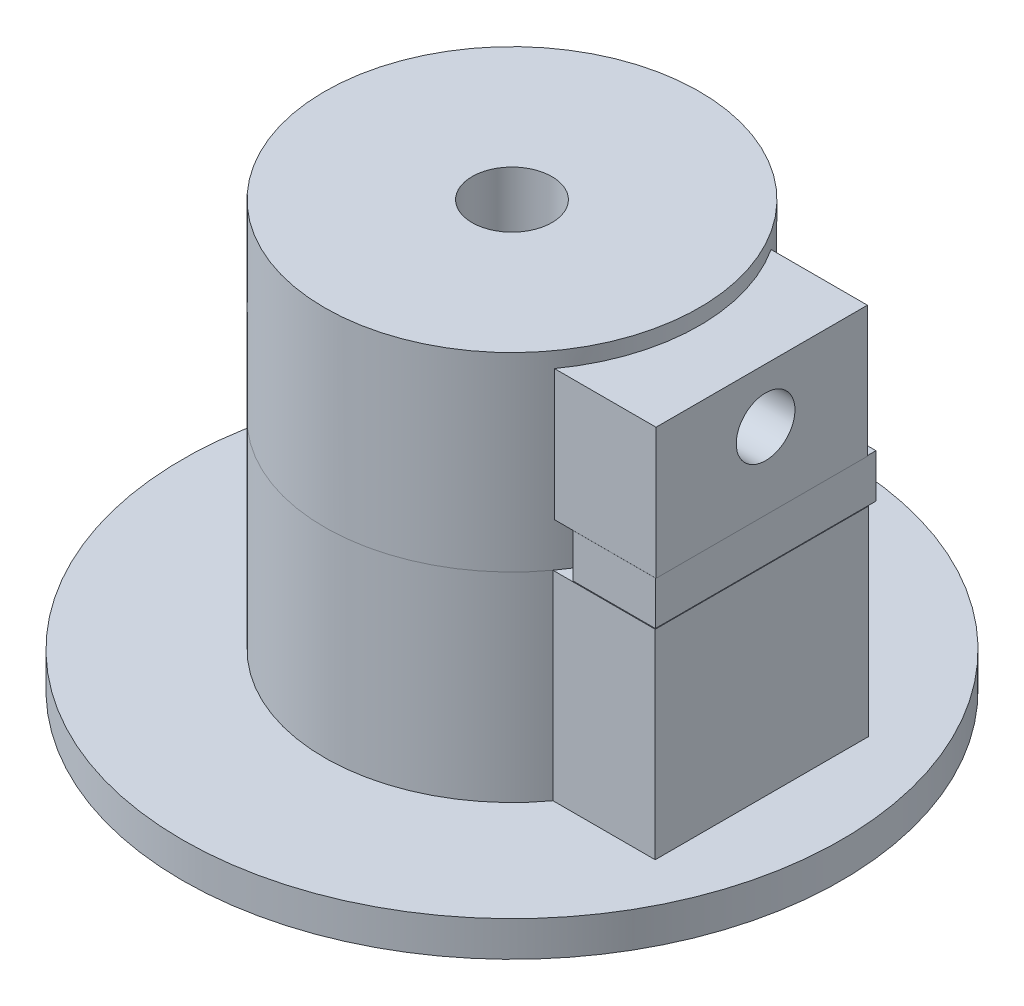
from build123d import *

# Parameters (mm, degrees)
SKETCH1_R                                      = 15.958
SHAFTHOLDERNEARMOTOR_DEPTH                     = 17.19
SKETCH2_R                                      = 3.4
SHAFTHOLE_DEPTH                                = 16.85
SKETCH5_W                                      = 1.550685087
SKETCH5_H                                      = 7.184215806
BOSS_EXTRUDE2_DEPTH                            = 13.55
SKETCH7_W                                      = 18.003976239
SKETCH7_H                                      = 11.144937805
BOSS_EXTRUDE3_DEPTH                            = 19
SKETCH6_R                                      = 2.5
BOLTHOLE_DEPTH                                 = 1
BOLTHOLE_DEPTH_BACK                            = 19
SKETCH10_R                                     = 50
BOSS_EXTRUDE4_DEPTH                            = 20
SKETCH12_R                                     = 43
SKETCH12_R_2                                   = 15.95790089
CUTTOREMVEEXCESSMATERIAL_DEPTH                 = 17
SKETCH13_R                                     = 50
SKETCH13_R_2                                   = 42.696683681
BOSS_EXTRUDE5_DEPTH                            = 17
SKETCH9_W                                      = 7.08573731
SKETCH9_H                                      = 8.730531823
NUTOPENING_DEPTH                               = 74.484692283
HEXCUT_DEPTH                                   = 7.08573731
SKETCH16_R                                     = 6
CUT_EXTRUDE7_DEPTH                             = 40
SKETCH19_R                                     = 12
CUT_EXTRUDE8_DEPTH                             = 5
SKETCH20_R                                     = 12
CUT_EXTRUDE9_DEPTH                             = 5
SKETCH22_R                                     = 12.553525499
CUT_EXTRUDE10_DEPTH                            = 5
SKETCH21_R                                     = 10
CUT_EXTRUDE11_DEPTH                            = 5
SKETCH23_R                                     = 11.965333231
CUT_EXTRUDE12_DEPTH                            = 5
SKETCH25_R                                     = 9.629681042
CUT_EXTRUDE13_DEPTH                            = 5
SKETCH26_R                                     = 15.012411299
CUT_EXTRUDE14_DEPTH                            = 5
SKETCH27_R                                     = 11.854712092
CUT_EXTRUDE15_DEPTH                            = 5
SKETCH28_W                                     = 8.838679887
SKETCH28_H                                     = 18.172415452
BOSS_EXTRUDE6_DEPTH                            = 17
SKETCH29_W                                     = 7.025540803
SKETCH29_H                                     = 18.786067296
BOSS_EXTRUDE7_DEPTH                            = 3.722722351
SKETCH31_R                                     = 26.336547497
CUT_EXTRUDE16_DEPTH                            = 1
SKETCH32_R                                     = 3.380332453
CUT_EXTRUDE17_DEPTH                            = 2
SKETCH33_R                                     = 63.32413164
SKETCH33_R_2                                   = 28.068575678
REMOVEOUTSIDEOFWHEEL_WOULDLIKETODISABLET_DEPTH = 80.806015003
CUTOUTWEDGETOMAKEBOTINSERTIONEASIER_DEPTH      = 7.085737
BOLTHOLDERDEPTHINCREASE_DEPTH                  = 7.08573731


with BuildPart() as part:
    # Sketch1 → ShaftHolderNearMotor (new body)
    with BuildSketch(Plane(origin=(0, 0, 0), x_dir=(1, 0, 0), z_dir=(0, 1, 0))):
        with Locations(Location((0, 0, 0), (0, 0, 270))):
            Circle(SKETCH1_R)
    extrude(amount=SHAFTHOLDERNEARMOTOR_DEPTH)

    # Sketch2 → ShaftHole (cut)
    with BuildSketch(Plane(origin=(0, 17.19, 0), x_dir=(1, 0, 0), z_dir=(0, 1, 0))):
        with Locations(Location((0, 0, 0), (0, 0, 270))):
            Circle(SKETCH2_R)
    extrude(amount=-SHAFTHOLE_DEPTH, mode=Mode.SUBTRACT)

    # Sketch5 → Boss-Extrude2 (add)
    with BuildSketch(Plane(origin=(0, 12.15, 0), x_dir=(1, 0, 0), z_dir=(0, 1, 0))):
        with Locations((3.375342544, 0.020519704)):
            Rectangle(SKETCH5_W, SKETCH5_H)
    extrude(amount=-BOSS_EXTRUDE2_DEPTH)

    # Sketch7 → Boss-Extrude3 (add)
    with BuildSketch(Plane.ZY.offset(-2.6)):
        with Locations((0.33027221, 9.295191254)):
            Rectangle(SKETCH7_W, SKETCH7_H)
    extrude(amount=-BOSS_EXTRUDE3_DEPTH)

    # Sketch6 → BoltHole (cut, two sides)
    with BuildSketch(Plane.ZY.offset(-2.6)) as bolthole_sk:
        with Locations(Location((0, 10.236925537, 0), (0, 0, 208.794122803))):
            Circle(SKETCH6_R)
    extrude(amount=BOLTHOLE_DEPTH, mode=Mode.SUBTRACT)
    extrude(bolthole_sk.sketch, amount=-BOLTHOLE_DEPTH_BACK, mode=Mode.SUBTRACT)

    # Sketch10 → Boss-Extrude4 (add)
    with BuildSketch(Plane.XZ):
        with Locations(Location((0, 0, 0), (0, 0, 270))):
            Circle(SKETCH10_R)
    extrude(amount=BOSS_EXTRUDE4_DEPTH)

    # Sketch12 → CutToRemveExcessMaterial (cut)
    with BuildSketch(Plane(origin=(0, 0, 0), x_dir=(1, 0, 0), z_dir=(0, 1, 0))):
        with Locations(Location((0, 0, 0), (0, 0, 270))):
            Circle(SKETCH12_R)
        with Locations(Location((0, 0, 0), (0, 0, 270))):
            Circle(SKETCH12_R_2, mode=Mode.SUBTRACT)
    extrude(amount=-CUTTOREMVEEXCESSMATERIAL_DEPTH, mode=Mode.SUBTRACT)

    # Sketch13 → Boss-Extrude5 (add)
    with BuildSketch(Plane(origin=(0, 0, 0), x_dir=(1, 0, 0), z_dir=(0, 1, 0))):
        with Locations(Location((0, 0, 0), (0, 0, 270))):
            Circle(SKETCH13_R)
        with Locations(Location((0, 0, 0), (0, 0, 270))):
            Circle(SKETCH13_R_2, mode=Mode.SUBTRACT)
    extrude(amount=BOSS_EXTRUDE5_DEPTH)

    # Sketch9 → NutOpening (cut, through all)
    with BuildSketch(Plane.XY):
        with Locations((8.411159077, 10.198209562)):
            Rectangle(SKETCH9_W, SKETCH9_H)
    extrude(amount=-NUTOPENING_DEPTH, mode=Mode.SUBTRACT)

    # Sketch14 → HexCut (cut)
    with BuildSketch(Plane.ZY.offset(-11.954027732)):
        Polygon((-4.731913408, 10.236925537), (-2.365956704, 6.138968317), (2.365956704, 6.138968317), (4.731913408, 10.236925537), (2.365956704, 14.334882757), (-2.365956704, 14.334882757), align=None)
    extrude(amount=HEXCUT_DEPTH, mode=Mode.SUBTRACT)

    # Sketch16 → Cut-Extrude7 (cut)
    with BuildSketch(Plane(origin=(21.6, 0, 0), x_dir=(0, 0, -1), z_dir=(1, 0, 0))):
        with Locations(Location((0, 10.236925537, 0), (0, 0, 180))):
            Circle(SKETCH16_R)
    extrude(amount=CUT_EXTRUDE7_DEPTH, mode=Mode.SUBTRACT)

    # Sketch19 → Cut-Extrude8 (cut)
    with BuildSketch(Plane(origin=(9.351145186, 0, 49.117777675), x_dir=(0.9823555534957298, 0, -0.18702290372063646), z_dir=(0.18702290372063649, 0, 0.9823555534957299))):
        with Locations((-6.553798813, -15.044376388)):
            Circle(SKETCH19_R)
    extrude(amount=-CUT_EXTRUDE8_DEPTH, mode=Mode.SUBTRACT)

    # Sketch20 → Cut-Extrude9 (cut)
    with BuildSketch(Plane(origin=(35.756785301, 0, 34.949281894), x_dir=(0.6989856378867483, 0, -0.7151357060223296), z_dir=(0.7151357060223296, 0, 0.6989856378867483))):
        with Locations((3.558365894, 19.429208609)):
            Circle(SKETCH20_R)
    extrude(amount=-CUT_EXTRUDE9_DEPTH, mode=Mode.SUBTRACT)

    # Sketch22 → Cut-Extrude10 (cut)
    with BuildSketch(Plane(origin=(34.949281894, 0, -35.756785301), x_dir=(-0.7151357060223288, 0, -0.698985637886749), z_dir=(0.698985637886749, 0, -0.7151357060223288))):
        with Locations((5.427738333, 18.490794011)):
            Circle(SKETCH22_R)
    extrude(amount=-CUT_EXTRUDE10_DEPTH, mode=Mode.SUBTRACT)

    # Sketch21 → Cut-Extrude11 (cut)
    with BuildSketch(Plane(origin=(49.117777675, 0, -9.351145186), x_dir=(-0.18702290372063798, 0, -0.9823555534957294), z_dir=(0.9823555534957294, 0, -0.18702290372063798))):
        with Locations((-4.791175632, -19.221882877)):
            Circle(SKETCH21_R)
    extrude(amount=-CUT_EXTRUDE11_DEPTH, mode=Mode.SUBTRACT)

    # Sketch23 → Cut-Extrude12 (cut)
    with BuildSketch(Plane(origin=(-0.570991135, 0, -49.996739585), x_dir=(-0.9999347916987428, 0, 0.011419822695298289), z_dir=(-0.011419822695298287, 0, -0.9999347916987427))):
        with Locations((4.525183767, -20.017770037)):
            Circle(SKETCH23_R)
    extrude(amount=-CUT_EXTRUDE12_DEPTH, mode=Mode.SUBTRACT)

    # Sketch25 → Cut-Extrude13 (cut)
    with BuildSketch(Plane(origin=(-41.343771844, 0, -28.119255498), x_dir=(-0.5623851099550343, 0, 0.8268754368711554), z_dir=(-0.8268754368711554, 0, -0.5623851099550343))):
        with Locations((-2.649823638, 18.643158668)):
            Circle(SKETCH25_R)
    extrude(amount=-CUT_EXTRUDE13_DEPTH, mode=Mode.SUBTRACT)

    # Sketch26 → Cut-Extrude14 (cut)
    with BuildSketch(Plane(origin=(-49.117777675, 0, 9.351145186), x_dir=(0.18702290372063635, 0, 0.9823555534957298), z_dir=(-0.9823555534957298, 0, 0.18702290372063635))):
        with Locations((-4.497650602, -19.126376963)):
            Circle(SKETCH26_R)
    extrude(amount=-CUT_EXTRUDE14_DEPTH, mode=Mode.SUBTRACT)

    # Sketch27 → Cut-Extrude15 (cut)
    with BuildSketch(Plane(origin=(-28.119255498, 0, 41.343771844), x_dir=(0.8268754368711555, 0, 0.562385109955034), z_dir=(-0.562385109955034, 0, 0.8268754368711555))):
        with Locations((-2.287517393, 17.62218093)):
            Circle(SKETCH27_R)
    extrude(amount=-CUT_EXTRUDE15_DEPTH, mode=Mode.SUBTRACT)

    # Sketch28 → Boss-Extrude6 (add)
    with BuildSketch(Plane.XZ):
        with Locations((17.180660057, 0.317955018)):
            Rectangle(SKETCH28_W, SKETCH28_H)
    extrude(amount=BOSS_EXTRUDE6_DEPTH)

    # Sketch29 → Boss-Extrude7 (add)
    with BuildSketch(Plane.XZ.offset(-3.722722351)):
        with Locations((18.03590553, -0.055280695)):
            Rectangle(SKETCH29_W, SKETCH29_H)
    extrude(amount=BOSS_EXTRUDE7_DEPTH)

    # Sketch31 → Cut-Extrude16 (cut)
    with BuildSketch(Plane(origin=(0, 17.19, 0), x_dir=(1, 0, 0), z_dir=(0, 1, 0))):
        Circle(SKETCH31_R)
    extrude(amount=-CUT_EXTRUDE16_DEPTH, mode=Mode.SUBTRACT)

    # Sketch32 → Cut-Extrude17 (cut)
    with BuildSketch(Plane(origin=(0, 14.867660156, 0), x_dir=(1, 0, 0), z_dir=(0, 1, 0))):
        Circle(SKETCH32_R)
    extrude(amount=-CUT_EXTRUDE17_DEPTH, mode=Mode.SUBTRACT)

    # Sketch33 → RemoveOutsideOfWheel_WouldLikeToDisableT (cut, through all)
    with BuildSketch(Plane.XZ.offset(20)):
        Circle(SKETCH33_R)
        with Locations(Location((0, 0, 0), (0, 0, 270))):
            Circle(SKETCH33_R_2, mode=Mode.SUBTRACT)
    extrude(amount=-REMOVEOUTSIDEOFWHEEL_WOULDLIKETODISABLET_DEPTH, mode=Mode.SUBTRACT)

    # Sketch37 → CutOutWedgeToMakeBotInsertionEasier (cut)
    with BuildSketch(Plane(origin=(4.868290422, 0, 0), x_dir=(0, 0, -1), z_dir=(1, 0, 0))):
        Polygon((15.197286349, 5.83294365), (14.323551181, 3.368491211), (5.921663956, 5.83294365), align=None)
    extrude(amount=CUTOUTWEDGETOMAKEBOTINSERTIONEASIER_DEPTH, mode=Mode.SUBTRACT)

    # Sketch38 → BoltHolderDepthIncrease (cut)
    with BuildSketch(Plane.ZY.offset(-11.954027732)):
        Polygon((2.365956704, 6.138968317), (3.237200261, 6.138968317), (5.739106701, 10.226173633), (3.237026282, 14.561036311), (2.365956704, 14.334882757), (4.731913408, 10.236925537), align=None)
    extrude(amount=BOLTHOLDERDEPTHINCREASE_DEPTH, mode=Mode.SUBTRACT)


solid = part.part
